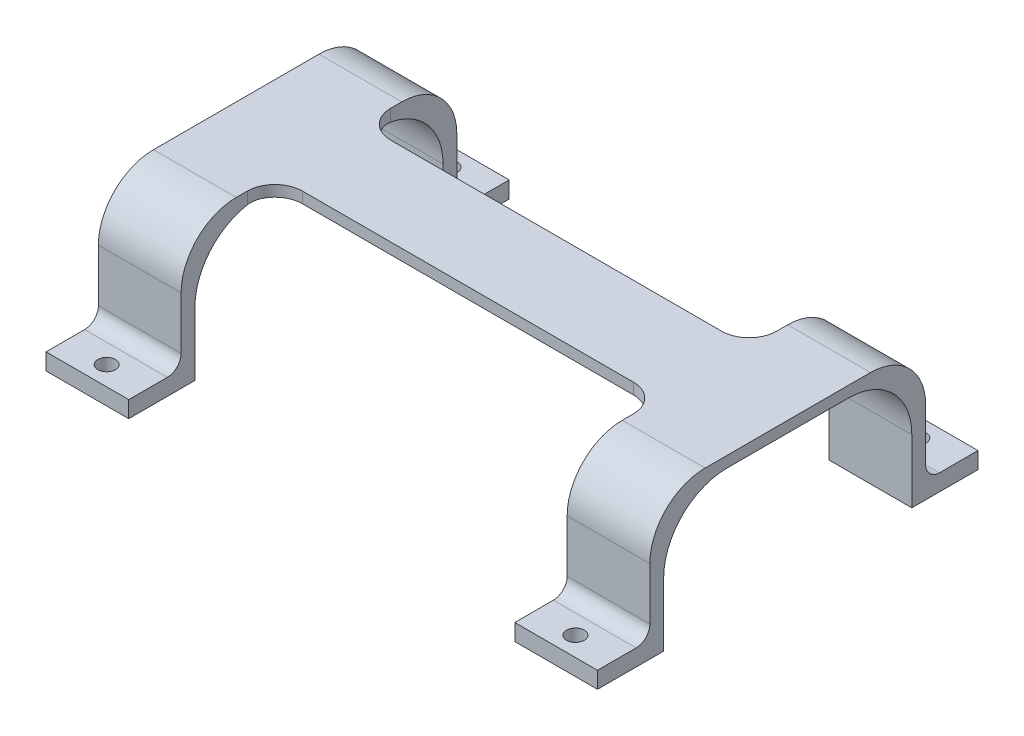
from build123d import *

# Parameters (mm, degrees)
BOSS_EXTRUDE1_DEPTH     = 50
SKETCH2_W               = 70
SKETCH2_H               = 26.5
CUT_EXTRUDE1_DEPTH      = 1
CUT_EXTRUDE1_DEPTH_BACK = 26
FILLET1_R               = 2.5
FILLET2_R               = 5
SKETCH3_R               = 1.6
CUT_EXTRUDE2_DEPTH      = 23.0000001
CUT_EXTRUDE2_DEPTH_BACK = 4


with BuildPart() as part:
    # Sketch1 → Boss-Extrude1 (new body, symmetric)
    with BuildSketch(Plane(origin=(0, 0, 0), x_dir=(0, 0, -1), z_dir=(1, 0, 0))):
        with BuildLine():
            Line((-11, 11.5), (11, 11.5))
            ThreePointArc((11, 11.5), (19.131727984, 8.131727984), (22.5, 0))
            Line((22.5, 0), (22.5, -11.5))
            Line((22.5, -11.5), (34.5, -11.5))
            Line((34.5, -11.5), (34.5, -8.5))
            Line((34.5, -8.5), (25, -8.5))
            Line((25, -8.5), (25, 0))
            Line((25, 0), (25, 3.5))
            ThreePointArc((25, 3.5), (22.071067812, 10.571067812), (15, 13.5))
            Line((15, 13.5), (-15, 13.5))
            ThreePointArc((-15, 13.5), (-22.071067812, 10.571067812), (-25, 3.5))
            Line((-25, 3.5), (-25, 0))
            Line((-25, 0), (-25, -8.5))
            Line((-25, -8.5), (-34.5, -8.5))
            Line((-34.5, -8.5), (-34.5, -11.5))
            Line((-34.5, -11.5), (-22.5, -11.5))
            Line((-22.5, -11.5), (-22.5, 0))
            ThreePointArc((-22.5, 0), (-19.131727984, 8.131727984), (-11, 11.5))
        make_face()
    extrude(amount=BOSS_EXTRUDE1_DEPTH, both=True)

    # Sketch2 → Cut-Extrude1 (cut, two sides)
    with BuildSketch(Plane(origin=(0, 13.5, 0), x_dir=(1, 0, 0), z_dir=(0, 1, 0))) as cut_extrude1_sk:
        with Locations((0, 21.25)):
            Rectangle(SKETCH2_W, SKETCH2_H)
        with Locations((0, -21.25)):
            Rectangle(SKETCH2_W, SKETCH2_H)
    extrude(amount=CUT_EXTRUDE1_DEPTH, mode=Mode.SUBTRACT)
    extrude(cut_extrude1_sk.sketch, amount=-CUT_EXTRUDE1_DEPTH_BACK, mode=Mode.SUBTRACT)

    # Fillet1
    fillet1_edges = [part.edges().sort_by_distance(p)[0] for p in [
        (42.5, -8.5, 25),
        (42.5, -8.5, -25),
        (-42.5, -8.5, 25),
        (-42.5, -8.5, -25),
    ]]
    fillet(fillet1_edges, radius=FILLET1_R)

    # Fillet2
    fillet2_edges = [part.edges().sort_by_distance(p)[0] for p in [
        (35, 12.5, -8),
        (35, 12.5, 8),
        (-35, 12.5, 8),
        (-35, 12.5, -8),
    ]]
    fillet(fillet2_edges, radius=FILLET2_R)

    # Sketch3 → Cut-Extrude2 (cut, two sides)
    with BuildSketch(Plane(origin=(0, -8.5, 0), x_dir=(1, 0, 0), z_dir=(0, 1, 0))) as cut_extrude2_sk:
        with Locations((42.5, -31)):
            Circle(SKETCH3_R)
        with Locations((42.5, 31)):
            Circle(SKETCH3_R)
        with Locations((-42.5, 31)):
            Circle(SKETCH3_R)
        with Locations((-42.5, -31)):
            Circle(SKETCH3_R)
    extrude(amount=CUT_EXTRUDE2_DEPTH, mode=Mode.SUBTRACT)
    extrude(cut_extrude2_sk.sketch, amount=-CUT_EXTRUDE2_DEPTH_BACK, mode=Mode.SUBTRACT)


solid = part.part
